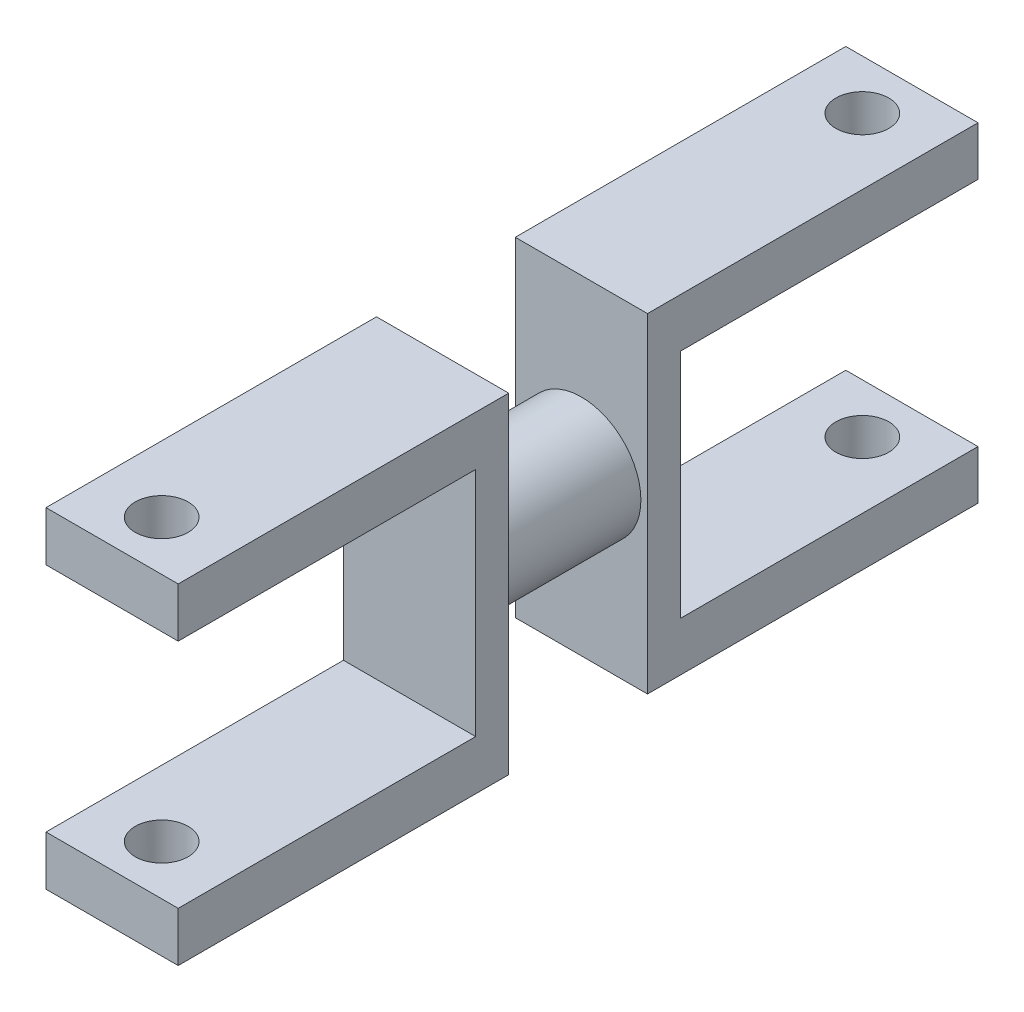
from build123d import *

# Parameters (mm, degrees)
SKETCH_1_R               = 3.6
SKETCH_1_R_2             = 2.8
EXTRUDE_1_DEPTH          = 8.4
SKETCH_2_W               = 8
SKETCH_2_H               = 19.939100818
EXTRUDE_2_DEPTH          = 20
SKETCH_3_W               = 8
SKETCH_3_H               = 20
EXTRUDE_3_DEPTH          = 20
SKETCH_4_W               = 8
SKETCH_4_H               = 14
CUT_EXTRUDE_2_DEPTH      = 18
SKETCH_5_W               = 8
SKETCH_5_H               = 14
CUT_EXTRUDE_3_DEPTH      = 18
SKETCH_6_R               = 1.6
CUT_EXTRUDE_4_DEPTH      = 10
CUT_EXTRUDE_4_DEPTH_BACK = 29


with BuildPart() as part:
    # 草图1 → 凸台-拉伸1 (new body)
    with BuildSketch(Plane.XY):
        Circle(SKETCH_1_R)
        Circle(SKETCH_1_R_2, mode=Mode.SUBTRACT)
    extrude(amount=EXTRUDE_1_DEPTH)

    # 草图2 → 凸台-拉伸2 (add)
    with BuildSketch(Plane(origin=(0, 0, 0), x_dir=(-1, 0, 0), z_dir=(0, 0, -1))):
        Rectangle(SKETCH_2_W, SKETCH_2_H)
    extrude(amount=EXTRUDE_2_DEPTH)

    # 草图3 → 凸台-拉伸3 (add)
    with BuildSketch(Plane.XY.offset(8.4)):
        Rectangle(SKETCH_3_W, SKETCH_3_H)
    extrude(amount=EXTRUDE_3_DEPTH)

    # 草图4 → 切除-拉伸2 (cut)
    with BuildSketch(Plane(origin=(0, 0, -20), x_dir=(-1, 0, 0), z_dir=(0, 0, -1))):
        Rectangle(SKETCH_4_W, SKETCH_4_H)
    extrude(amount=-CUT_EXTRUDE_2_DEPTH, mode=Mode.SUBTRACT)

    # 草图5 → 切除-拉伸3 (cut)
    with BuildSketch(Plane.XY.offset(28.4)):
        Rectangle(SKETCH_5_W, SKETCH_5_H)
    extrude(amount=-CUT_EXTRUDE_3_DEPTH, mode=Mode.SUBTRACT)

    # 草图6 → 切除-拉伸4 (cut, two sides)
    with BuildSketch(Plane(origin=(0, 9.969550409, 0), x_dir=(1, 0, 0), z_dir=(0, 1, 0))) as cut_extrude_4_sk:
        with Locations((0, 17)):
            Circle(SKETCH_6_R)
        with Locations((0, -25.4)):
            Circle(SKETCH_6_R)
    extrude(amount=CUT_EXTRUDE_4_DEPTH, mode=Mode.SUBTRACT)
    extrude(cut_extrude_4_sk.sketch, amount=-CUT_EXTRUDE_4_DEPTH_BACK, mode=Mode.SUBTRACT)


solid = part.part
